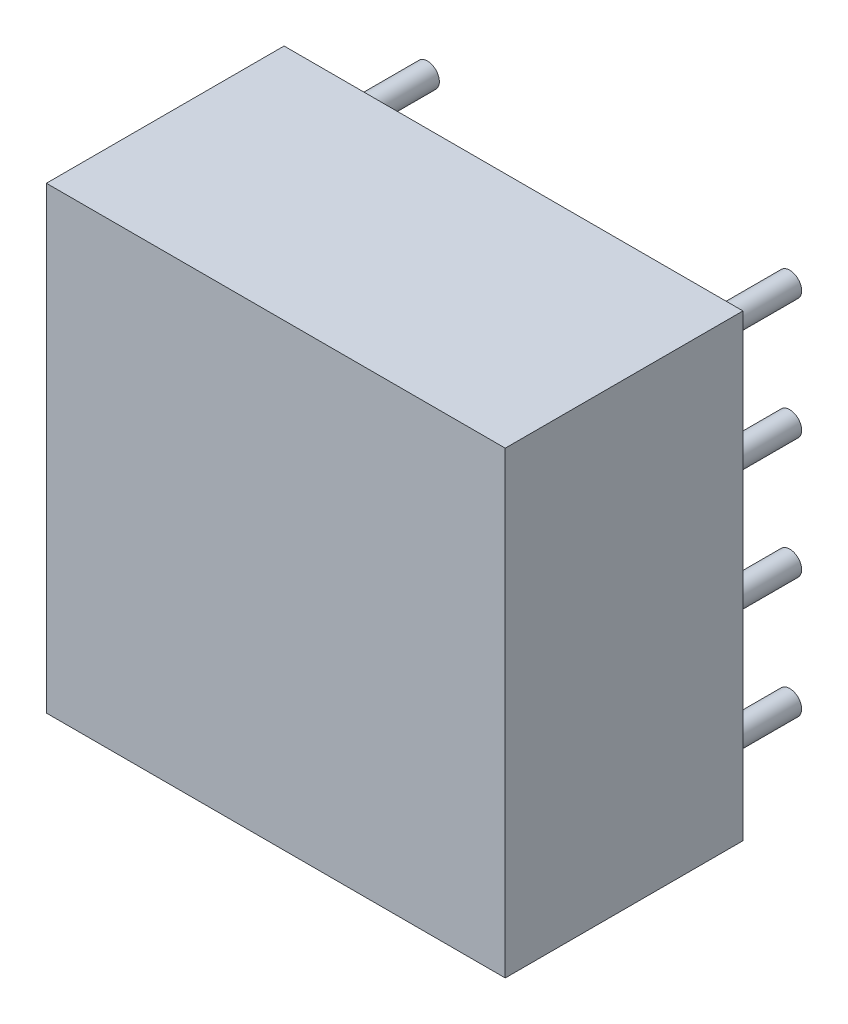
from build123d import *

# Parameters (mm, degrees)
SKETCH1_W               = 9.652
SKETCH1_H               = 9.652
COMPONENT_OUTLINE_DEPTH = 5
SKETCH2_R               = 0.25
EXTRUDE_1_DEPTH         = 2
SKETCH3_R               = 0.25
EXTRUDE_2_DEPTH         = 2
SKETCH4_R               = 0.25
EXTRUDE_3_DEPTH         = 2
SKETCH5_R               = 0.25
EXTRUDE_4_DEPTH         = 2
SKETCH6_R               = 0.25
EXTRUDE_5_DEPTH         = 2
SKETCH7_R               = 0.25
EXTRUDE_6_DEPTH         = 2
SKETCH8_R               = 0.25
EXTRUDE_7_DEPTH         = 2
SKETCH9_R               = 0.25
EXTRUDE_8_DEPTH         = 2


with BuildPart() as part:
    # Sketch1 → Component_Outline (new body)
    with BuildSketch(Plane.XY):
        with Locations((3.81, 3.81)):
            Rectangle(SKETCH1_W, SKETCH1_H)
    extrude(amount=COMPONENT_OUTLINE_DEPTH)


with BuildPart() as body_2:
    # Sketch2 → Extrude 1 (new body)
    with BuildSketch(Plane.XY):
        Circle(SKETCH2_R)
    extrude(amount=-EXTRUDE_1_DEPTH)


with BuildPart() as body_3:
    # Sketch3 → Extrude 2 (new body)
    with BuildSketch(Plane.XY):
        with Locations((0, 2.54)):
            Circle(SKETCH3_R)
    extrude(amount=-EXTRUDE_2_DEPTH)


with BuildPart() as body_4:
    # Sketch4 → Extrude 3 (new body)
    with BuildSketch(Plane.XY):
        with Locations((0, 5.08)):
            Circle(SKETCH4_R)
    extrude(amount=-EXTRUDE_3_DEPTH)


with BuildPart() as body_5:
    # Sketch5 → Extrude 4 (new body)
    with BuildSketch(Plane.XY):
        with Locations((0, 7.62)):
            Circle(SKETCH5_R)
    extrude(amount=-EXTRUDE_4_DEPTH)


with BuildPart() as body_6:
    # Sketch6 → Extrude 5 (new body)
    with BuildSketch(Plane.XY):
        with Locations((7.62, 0)):
            Circle(SKETCH6_R)
    extrude(amount=-EXTRUDE_5_DEPTH)


with BuildPart() as body_7:
    # Sketch7 → Extrude 6 (new body)
    with BuildSketch(Plane.XY):
        with Locations((7.62, 2.54)):
            Circle(SKETCH7_R)
    extrude(amount=-EXTRUDE_6_DEPTH)


with BuildPart() as body_8:
    # Sketch8 → Extrude 7 (new body)
    with BuildSketch(Plane.XY):
        with Locations((7.62, 5.08)):
            Circle(SKETCH8_R)
    extrude(amount=-EXTRUDE_7_DEPTH)


with BuildPart() as body_9:
    # Sketch9 → Extrude 8 (new body)
    with BuildSketch(Plane.XY):
        with Locations((7.62, 7.62)):
            Circle(SKETCH9_R)
    extrude(amount=-EXTRUDE_8_DEPTH)


solid = Compound([part.part, body_2.part, body_3.part, body_4.part, body_5.part, body_6.part, body_7.part, body_8.part, body_9.part])
